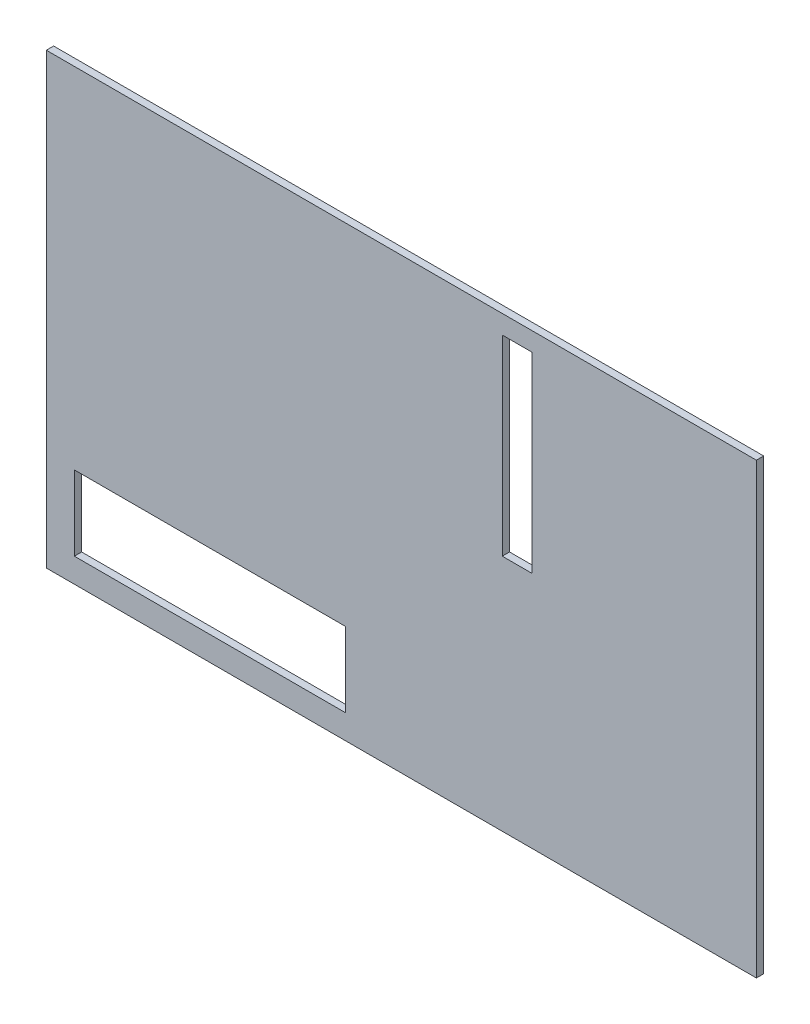
from build123d import *

# Parameters (mm, degrees)
SKETCH1_W           = 96.52
SKETCH1_H           = 60.96
BOSS_EXTRUDE1_DEPTH = 0.9906
CUT_EXTRUDE1_REACH  = 2.991
SKETCH2_W           = 36.83
SKETCH2_H           = 10.16
SKETCH2_W_2         = 4.064
SKETCH2_H_2         = 26.035


with BuildPart() as part:
    # Sketch1 → Boss-Extrude1 (new body)
    with BuildSketch(Plane.XY):
        Rectangle(SKETCH1_W, SKETCH1_H)
    extrude(amount=BOSS_EXTRUDE1_DEPTH)

    # Sketch2 → Cut-Extrude1 (cut, up to next)
    with BuildSketch(Plane.XY.offset(0.9906), mode=Mode.PRIVATE) as cut_extrude1_sk1:
        with Locations((-26.035, -22.098)):
            Rectangle(SKETCH2_W, SKETCH2_H)
    cut_extrude1_tool1 = extrude(cut_extrude1_sk1.sketch, amount=-CUT_EXTRUDE1_REACH, mode=Mode.PRIVATE) & part.part
    add(cut_extrude1_tool1.solids().sort_by_distance((-26.035, -22.098, 0.9906))[0], mode=Mode.SUBTRACT)
    # Sketch2 → Cut-Extrude1 (cut, up to next)
    with BuildSketch(Plane.XY.offset(0.9906), mode=Mode.PRIVATE) as cut_extrude1_sk2:
        with Locations((15.748, 14.9225)):
            Rectangle(SKETCH2_W_2, SKETCH2_H_2)
    cut_extrude1_tool2 = extrude(cut_extrude1_sk2.sketch, amount=-CUT_EXTRUDE1_REACH, mode=Mode.PRIVATE) & part.part
    add(cut_extrude1_tool2.solids().sort_by_distance((15.748, 14.9225, 0.9906))[0], mode=Mode.SUBTRACT)


solid = part.part
